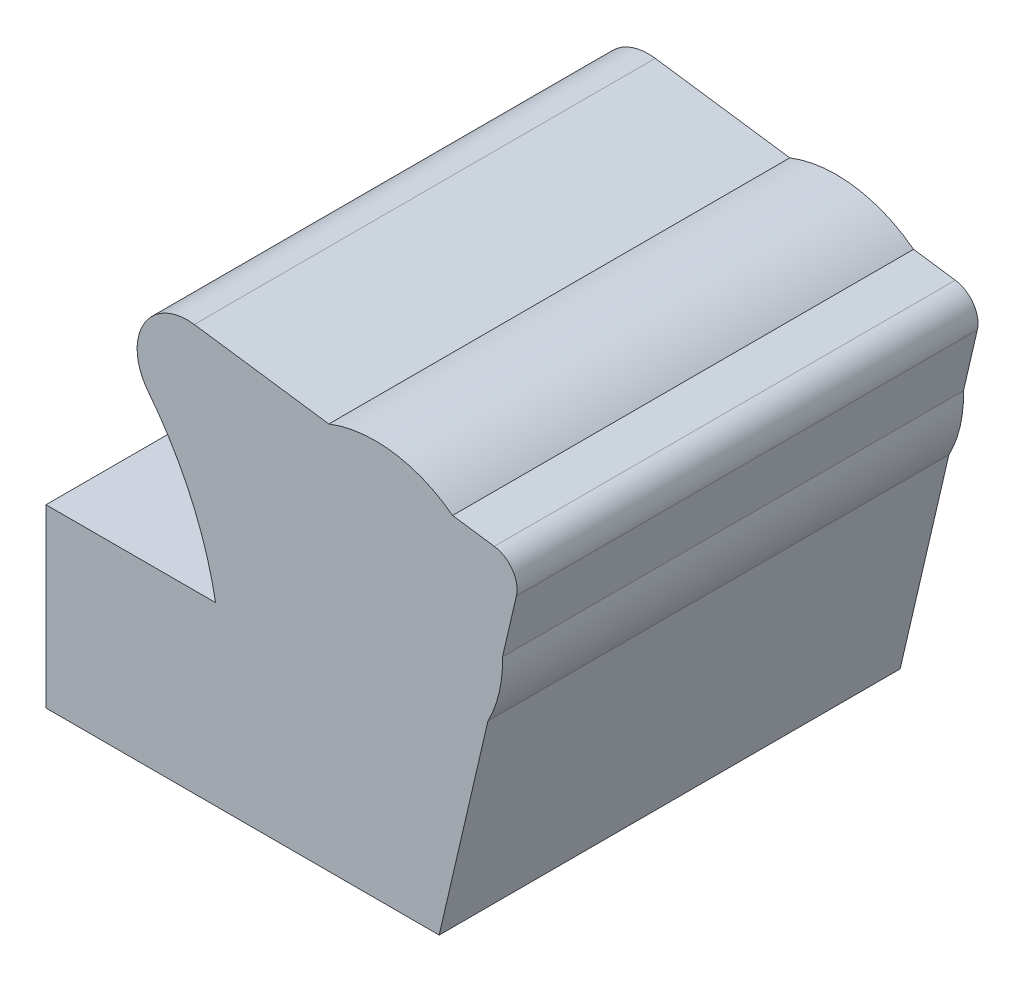
from build123d import *

# Parameters (mm, degrees)
SKETCH_1_R                     = 27.60110162
EXTRUDE_1_DEPTH                = 50
SPLIT_BODIES_1_SURFACE_1_BACK  = 232.061
SPLIT_BODIES_1_SURFACE_1_DEPTH = 464.122
SPLIT_BODIES_1_SURFACE_2_BACK  = 232.061
SPLIT_BODIES_1_SURFACE_2_DEPTH = 464.122


with BuildPart() as part:
    # 草图1 → 凸台-拉伸1 (new, symmetric)
    with BuildSketch(Plane.XY):
        with Locations((126.841, 106.3205)):
            Circle(SKETCH_1_R)
        with BuildLine():
            Line((0, 29.556947787), (33.841128496, 29.556947787))
            Line((33.841128496, 29.556947787), (55.404404979, 43.133825573))
            Line((55.404404979, 43.133825573), (55.404404979, 86.167316842))
            Line((55.404404979, 86.167316842), (92.202864513, 86.167316842))
            ThreePointArc((92.202864513, 86.167316842), (86.826289789, 103.279036613), (77.508707697, 118.605522617))
            ThreePointArc((77.508707697, 118.605522617), (76.622434757, 130.759815978), (87.569736188, 136.114152372))
            Line((87.569736188, 136.114152372), (152.661112554, 126.977376967))
            ThreePointArc((152.661112554, 126.977376967), (156.581939246, 124.549931981), (157.437634447, 120.018579331))
            Line((157.437634447, 120.018579331), (140.698476255, 47.962391292))
            Line((140.698476255, 47.962391292), (125.156200351, 47.962391292))
            Line((125.156200351, 47.962391292), (116.770080258, 26.493923855))
            Line((116.770080258, 26.493923855), (133.542320443, 26.493923855))
            Line((133.542320443, 26.493923855), (144.001, 0))
            Line((144.001, 0), (0, 0))
            Line((0, 0), (0, 29.556947787))
        make_face()
    extrude(amount=EXTRUDE_1_DEPTH, both=True)


with BuildPart() as body_2:
    # Split Bodies 1: the piece behind the surface
    add(part.part)
    # Split Bodies 1 surface: a surface, the sketch's curves swept straight by 464.122 mm
    with BuildLine(Plane.XY.offset(50).offset(-SPLIT_BODIES_1_SURFACE_1_BACK), mode=Mode.PRIVATE) as split_bodies_1_surface_1_path:
        Line((125.156200351, 47.962391292), (37.921543342, 47.962391292))
    split_bodies_1_surface_1 = Shell.extrude(split_bodies_1_surface_1_path.wire(), (0 * SPLIT_BODIES_1_SURFACE_1_DEPTH, 0 * SPLIT_BODIES_1_SURFACE_1_DEPTH, 1 * SPLIT_BODIES_1_SURFACE_1_DEPTH))
    split(bisect_by=split_bodies_1_surface_1, keep=Keep.BOTTOM)


with BuildPart() as part_1:
    add(part.part)

    # Split Bodies 1: split by a surface, the side it looks to stays
    # Split Bodies 1 surface: a surface, the sketch's curves swept straight by 464.122 mm
    with BuildLine(Plane.XY.offset(50).offset(-SPLIT_BODIES_1_SURFACE_2_BACK), mode=Mode.PRIVATE) as split_bodies_1_surface_2_path:
        Line((125.156200351, 47.962391292), (37.921543342, 47.962391292))
    split_bodies_1_surface_2 = Shell.extrude(split_bodies_1_surface_2_path.wire(), (0 * SPLIT_BODIES_1_SURFACE_2_DEPTH, 0 * SPLIT_BODIES_1_SURFACE_2_DEPTH, 1 * SPLIT_BODIES_1_SURFACE_2_DEPTH))
    split(bisect_by=split_bodies_1_surface_2, keep=Keep.TOP)


solid = body_2.part
